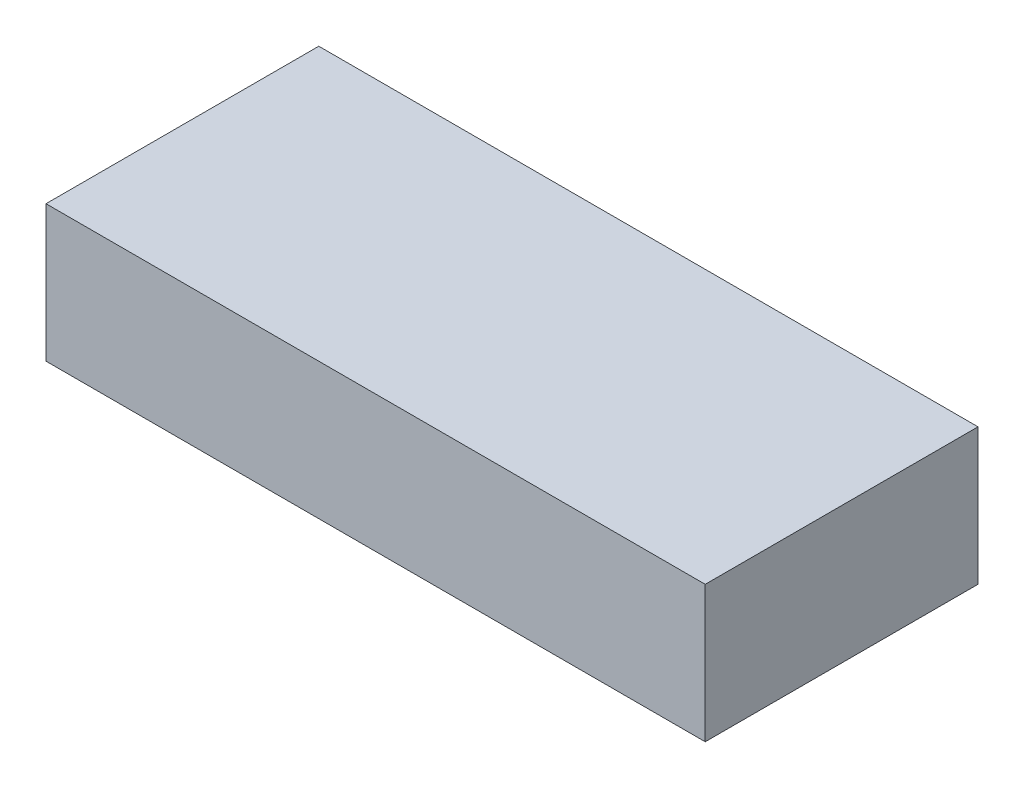
from build123d import *

# Parameters (mm, degrees)
SKETCH1_W           = 92.075
SKETCH1_H           = 38.1
BOSS_EXTRUDE1_DEPTH = 19.05


with BuildPart() as part:
    # Sketch1 → Boss-Extrude1 (new body)
    with BuildSketch(Plane(origin=(0, 0, 0), x_dir=(1, 0, 0), z_dir=(0, 1, 0))):
        with Locations((46.0375, 19.05)):
            Rectangle(SKETCH1_W, SKETCH1_H)
    extrude(amount=BOSS_EXTRUDE1_DEPTH)


solid = part.part
